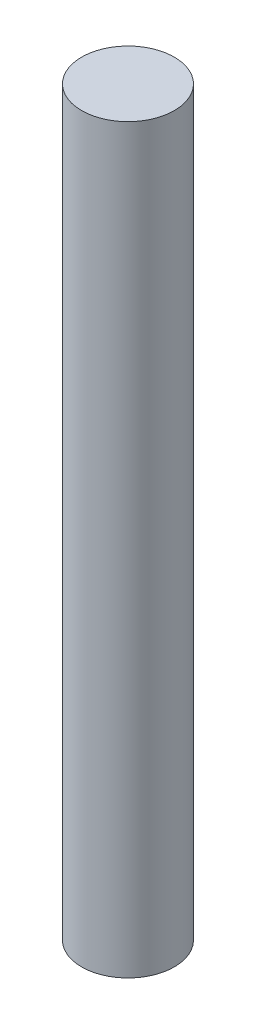
from build123d import *

# Parameters (mm, degrees)
SKETCH1_R           = 2
BOSS_EXTRUDE1_DEPTH = 32


with BuildPart() as part:
    # Sketch1 → Boss-Extrude1 (new body)
    with BuildSketch(Plane(origin=(0, 0, 0), x_dir=(1, 0, 0), z_dir=(0, 1, 0))):
        Circle(SKETCH1_R)
    extrude(amount=BOSS_EXTRUDE1_DEPTH)


solid = part.part
